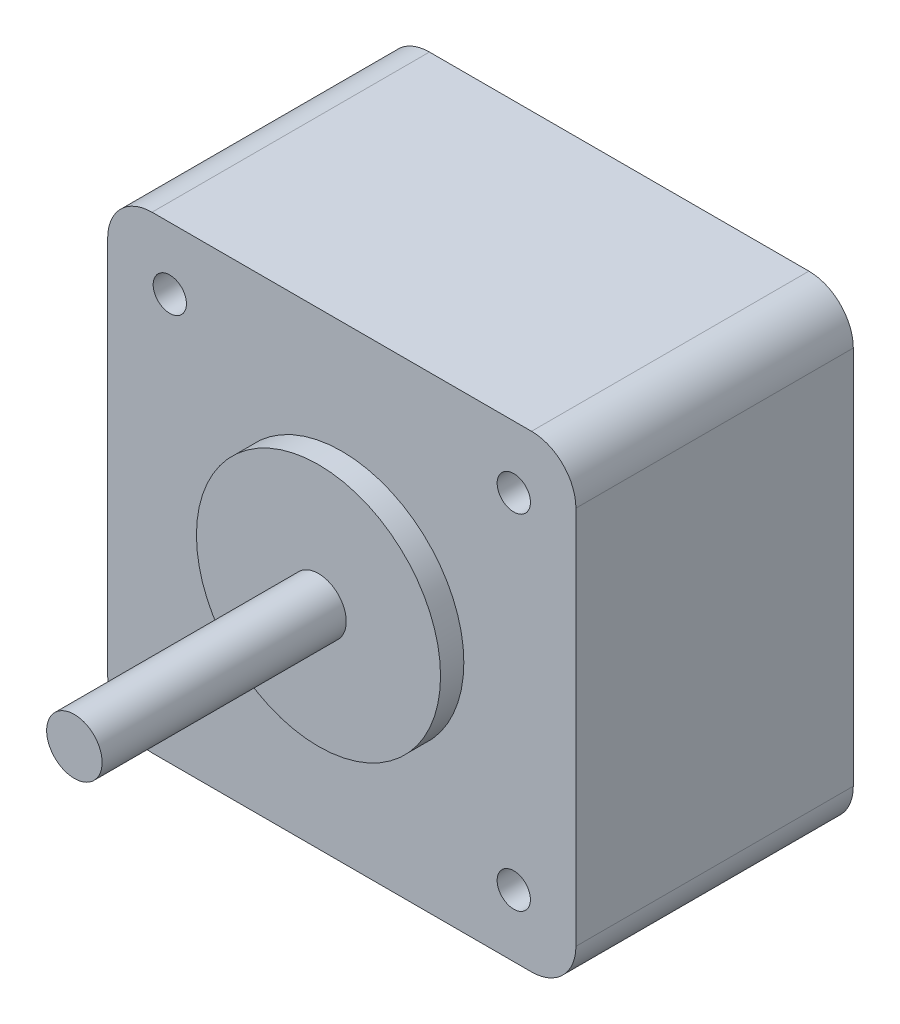
from build123d import *

# Parameters (mm, degrees)
SKIZZE1_W                       = 42.2
SKIZZE1_H                       = 42.2
AUFSATZ_LINEAR_AUSTRAGEN1_DEPTH = 25
SKIZZE2_R                       = 11
AUFSATZ_LINEAR_AUSTRAGEN2_DEPTH = 2.1
SKIZZE3_R                       = 2.5
AUFSATZ_LINEAR_AUSTRAGEN3_DEPTH = 22
SKIZZE4_R                       = 1.5
SCHNITT_LINEAR_AUSTRAGEN1_DEPTH = 4
FILLET1_R                       = 4


with BuildPart() as part:
    # Skizze1 → Aufsatz-Linear austragen1 (new body)
    with BuildSketch(Plane.XY):
        Rectangle(SKIZZE1_W, SKIZZE1_H)
    extrude(amount=AUFSATZ_LINEAR_AUSTRAGEN1_DEPTH)

    # Skizze2 → Aufsatz-Linear austragen2 (add)
    with BuildSketch(Plane.XY.offset(25)):
        Circle(SKIZZE2_R)
    extrude(amount=AUFSATZ_LINEAR_AUSTRAGEN2_DEPTH)

    # Skizze3 → Aufsatz-Linear austragen3 (add)
    with BuildSketch(Plane.XY.offset(27.1)):
        Circle(SKIZZE3_R)
    extrude(amount=AUFSATZ_LINEAR_AUSTRAGEN3_DEPTH)

    # Skizze4 → Schnitt-Linear austragen1 (cut)
    with BuildSketch(Plane.XY.offset(25)):
        with Locations((-15.5, 15.5)):
            Circle(SKIZZE4_R)
        with Locations((15.5, 15.5)):
            Circle(SKIZZE4_R)
        with Locations((15.5, -15.5)):
            Circle(SKIZZE4_R)
        with Locations((-15.5, -15.5)):
            Circle(SKIZZE4_R)
    extrude(amount=-SCHNITT_LINEAR_AUSTRAGEN1_DEPTH, mode=Mode.SUBTRACT)

    # Fillet1
    fillet1_edges = [part.edges().sort_by_distance(p)[0] for p in [
        (21.1, -21.1, 12.5),
        (-21.1, 21.1, 12.5),
        (21.1, 21.1, 12.5),
        (-21.1, -21.1, 12.5),
    ]]
    fillet(fillet1_edges, radius=FILLET1_R)


solid = part.part
